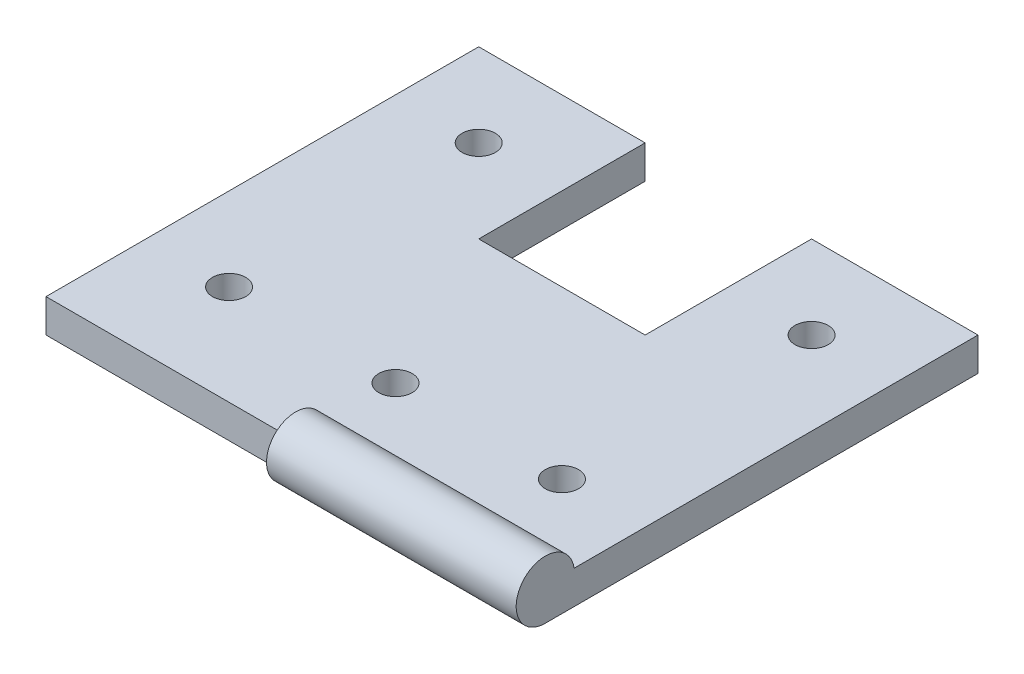
from build123d import *

# Parameters (mm, degrees)
SKETCH1_W           = 15
SKETCH1_H           = 13
BOSS_EXTRUDE1_DEPTH = 1
SKETCH2_R           = 0.875
BOSS_EXTRUDE2_DEPTH = 7.5
SKETCH3_W           = 5
SKETCH3_H           = 5
CUT_EXTRUDE1_DEPTH  = 10
SKETCH4_R           = 0.5
CUT_EXTRUDE2_DEPTH  = 2


with BuildPart() as part:
    # Sketch1 → Boss-Extrude1 (new body)
    with BuildSketch(Plane(origin=(0, 0, 0), x_dir=(1, 0, 0), z_dir=(0, 1, 0))):
        with Locations((10.569631841, -166.54341444)):
            Rectangle(SKETCH1_W, SKETCH1_H)
    extrude(amount=BOSS_EXTRUDE1_DEPTH)

    # Sketch2 → Boss-Extrude2 (add)
    with BuildSketch(Plane(origin=(18.069631841, 0, 0), x_dir=(0, 0, -1), z_dir=(1, 0, 0))):
        with Locations((-173.04341444, 0.875)):
            Circle(SKETCH2_R)
    extrude(amount=-BOSS_EXTRUDE2_DEPTH)

    # Sketch3 → Cut-Extrude1 (cut)
    with BuildSketch(Plane(origin=(0, 0, 0), x_dir=(-1, 0, 0), z_dir=(0, -1, 0))):
        with Locations((-10.569631841, -162.54341444)):
            Rectangle(SKETCH3_W, SKETCH3_H)
    extrude(amount=-CUT_EXTRUDE1_DEPTH, mode=Mode.SUBTRACT)

    # Sketch4 → Cut-Extrude2 (cut, through all)
    with BuildSketch(Plane(origin=(0, 1, 0), x_dir=(1, 0, 0), z_dir=(0, 1, 0))):
        with Locations((15.569631841, -162.54341444)):
            Circle(SKETCH4_R)
        with Locations((15.569631841, -170.04341444)):
            Circle(SKETCH4_R)
        with Locations((10.569631841, -170.04341444)):
            Circle(SKETCH4_R)
        with Locations((5.569631841, -170.04341444)):
            Circle(SKETCH4_R)
        with Locations((5.569631841, -162.54341444)):
            Circle(SKETCH4_R)
    extrude(amount=-CUT_EXTRUDE2_DEPTH, mode=Mode.SUBTRACT)


solid = part.part
